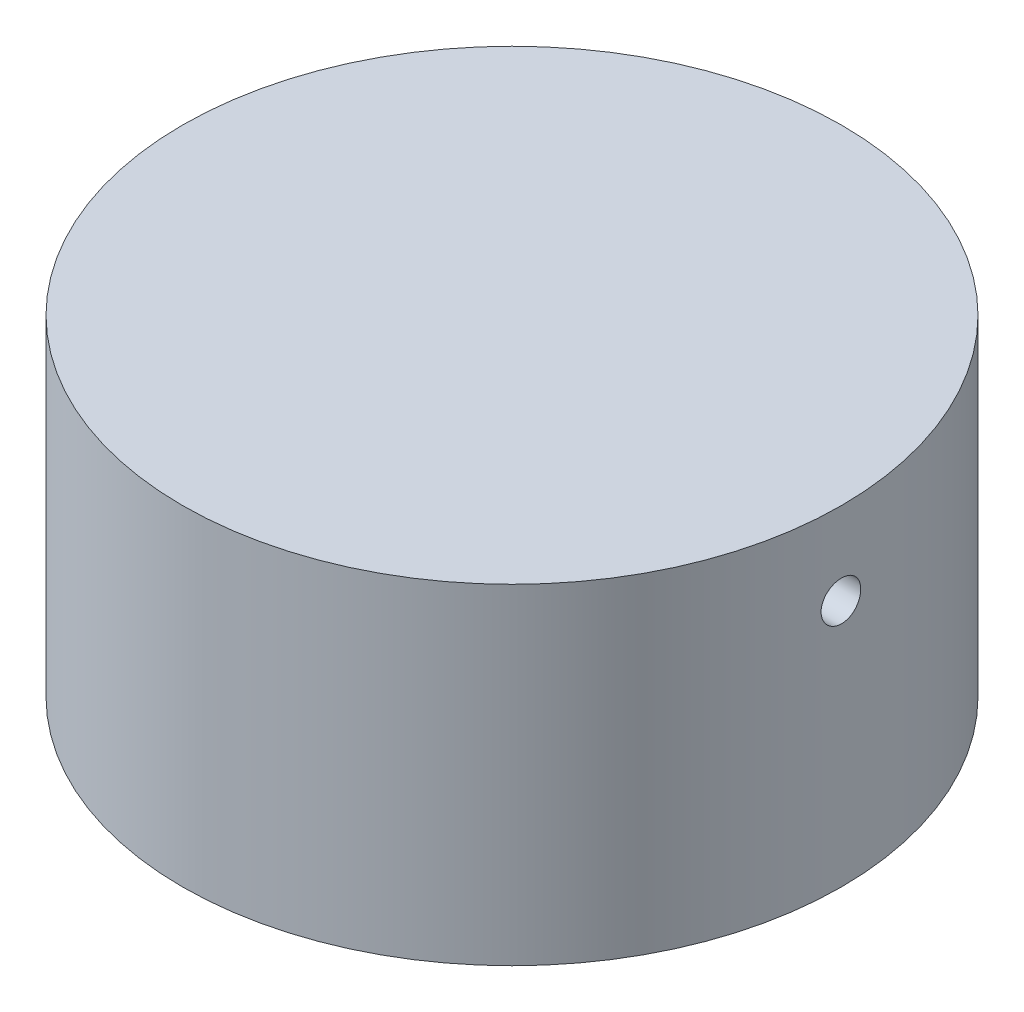
from build123d import *

# Parameters (mm, degrees)
SKETCH1_R           = 19.95
BOSS_EXTRUDE1_DEPTH = 20
SKETCH6_R           = 1.2
SKETCH12_R          = 1.9
BOSS_EXTRUDE2_DEPTH = 10
SKETCH13_R          = 0.9
CUT_EXTRUDE1_DEPTH  = 10
SKETCH14_R          = 1.65
CUT_EXTRUDE2_DEPTH  = 5.5


with BuildPart() as part:
    # Sketch1 → Boss-Extrude1 (new body)
    with BuildSketch(Plane(origin=(0, 0, 0), x_dir=(1, 0, 0), z_dir=(0, 1, 0))):
        Circle(SKETCH1_R)
    extrude(amount=BOSS_EXTRUDE1_DEPTH)

    # Cut-Sweep2: sweep along a path in Sketch5
    with BuildLine(Plane.XY) as cut_sweep2_path:
        Line((0, 0), (0, 10))
        ThreePointArc((0, 10), (1.464466094, 13.535533906), (5, 15))
        Line((5, 15), (19.95, 15))
    # Sketch6 → Cut-Sweep2 (sweep, cut)
    with BuildSketch(Plane(origin=(0, 0, 0), x_dir=(-1, 0, 0), z_dir=(0, -1, 0))):
        Circle(SKETCH6_R)
    sweep(path=cut_sweep2_path.line, mode=Mode.SUBTRACT)

    # Sketch12 → Boss-Extrude2 (add)
    with BuildSketch(Plane(origin=(0, 0, 0), x_dir=(-1, 0, 0), z_dir=(0, -1, 0))):
        Circle(SKETCH12_R)
    extrude(amount=BOSS_EXTRUDE2_DEPTH)

    # Sketch13 → Cut-Extrude1 (cut)
    with BuildSketch(Plane(origin=(0, -10, 0), x_dir=(-1, 0, 0), z_dir=(0, -1, 0))):
        Circle(SKETCH13_R)
    extrude(amount=-CUT_EXTRUDE1_DEPTH, mode=Mode.SUBTRACT)

    # Sketch14 → Cut-Extrude2 (cut)
    with BuildSketch(Plane(origin=(0, 0, 0), x_dir=(-1, 0, 0), z_dir=(0, -1, 0))):
        with Locations((-15, 0)):
            Circle(SKETCH14_R)
        with Locations((0, 15)):
            Circle(SKETCH14_R)
        with Locations((0, -15)):
            Circle(SKETCH14_R)
        with Locations((15, 0)):
            Circle(SKETCH14_R)
    extrude(amount=-CUT_EXTRUDE2_DEPTH, mode=Mode.SUBTRACT)


solid = part.part
